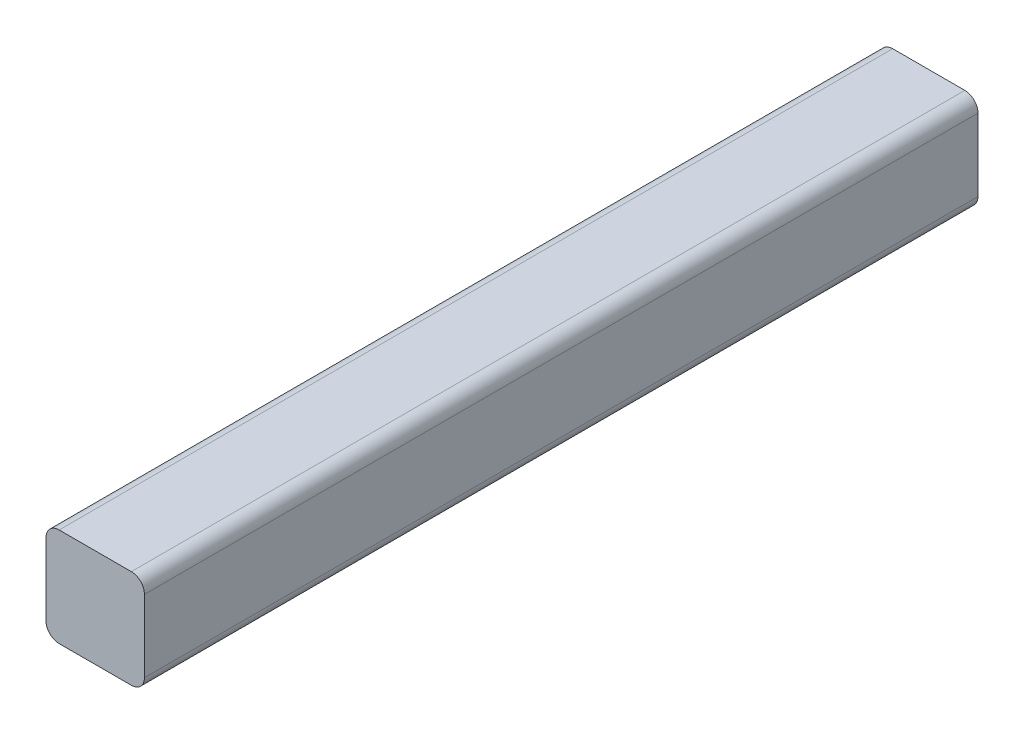
from build123d import *

# Parameters (mm, degrees)
SKETCH1_W           = 15
SKETCH1_H           = 15
BOSS_EXTRUDE1_DEPTH = 127
FILLET1_R           = 2


with BuildPart() as part:
    # Sketch1 → Boss-Extrude1 (new body)
    with BuildSketch(Plane.XY):
        Rectangle(SKETCH1_W, SKETCH1_H)
    extrude(amount=BOSS_EXTRUDE1_DEPTH)

    # Fillet1
    fillet1_edges = [part.edges().sort_by_distance(p)[0] for p in [
        (-7.5, 7.5, 63.5),
        (7.5, 7.5, 63.5),
        (7.5, -7.5, 63.5),
        (-7.5, -7.5, 63.5),
    ]]
    fillet(fillet1_edges, radius=FILLET1_R)


solid = part.part
